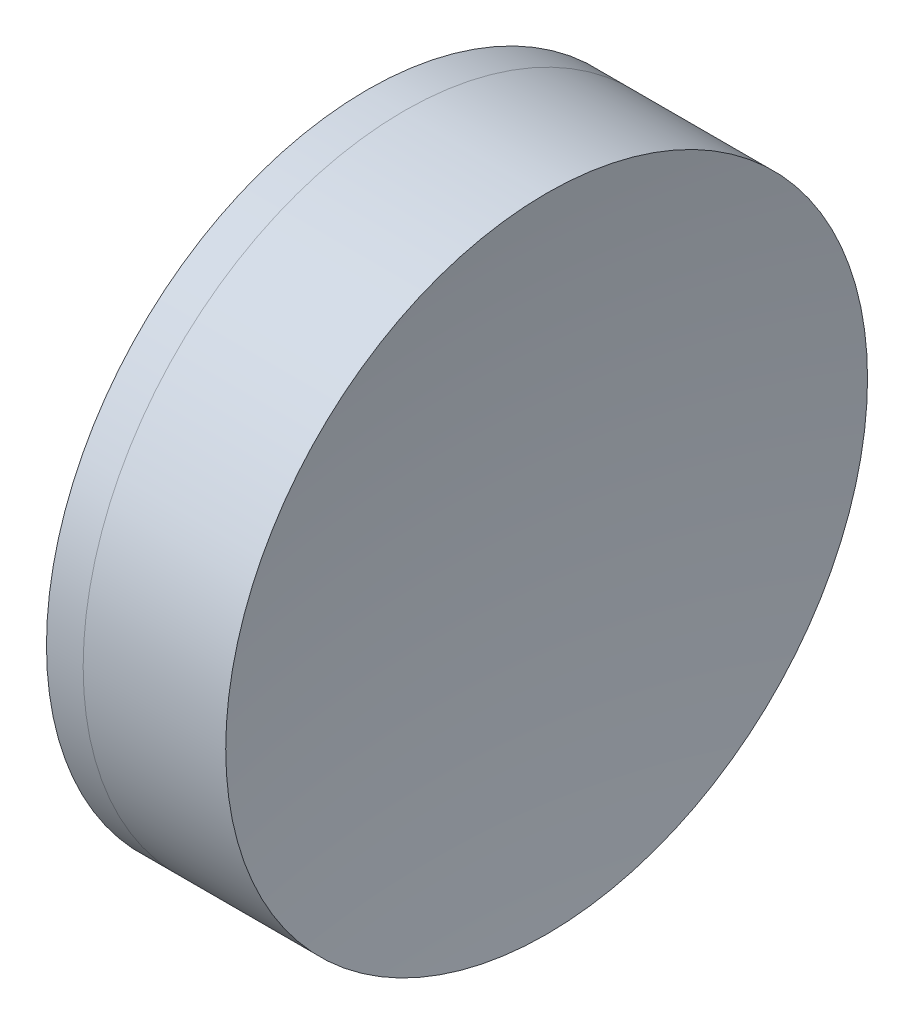
from build123d import *


with BuildPart() as part:
    # 草图1 one side → 旋转1 (revolve)
    with BuildSketch(Plane(origin=(0, 0, 0), x_dir=(1, 0, 0), z_dir=(0, 1, 0)), mode=Mode.PRIVATE) as revolve_1_sk:
        with BuildLine():
            ThreePointArc((37.491337365, 12.7), (35.058532397, 6.556003243), (34.23024643, 0))
            Line((34.23024643, 0), (41.83024643, 0))
            ThreePointArc((41.83024643, 0), (41.09948073, 6.511971596), (38.943536147, 12.7))
            Line((38.943536147, 12.7), (37.491337365, 12.7))
        make_face()
    revolve(revolve_1_sk.sketch.rotate(Axis((-0.816062176, 0, 0), (1, 0, 0)), 180), axis=Axis((-0.816062176, 0, 0), (1, 0, 0)))  # turned: the seam where the file's is


with BuildPart() as body_2:
    # 草图2 one side → 旋转2 (revolve)
    with BuildSketch(Plane(origin=(0, 0, 0), x_dir=(1, 0, 0), z_dir=(0, 1, 0)), mode=Mode.PRIVATE) as revolve_2_sk:
        with BuildLine():
            Line((44.585275162, 12.7), (38.943536147, 12.7))
            ThreePointArc((38.943536147, 12.7), (41.09948073, 6.511971596), (41.83024643, 0))
            Line((41.83024643, 0), (43.63024643, 0))
            ThreePointArc((43.63024643, 0), (43.8693402, 6.367929017), (44.585275162, 12.7))
        make_face()
    revolve(revolve_2_sk.sketch.rotate(Axis((-0.551919993, 0, 0), (1, 0, 0)), 180), axis=Axis((-0.551919993, 0, 0), (1, 0, 0)))  # turned: the seam where the file's is


solid = Compound([part.part, body_2.part])
